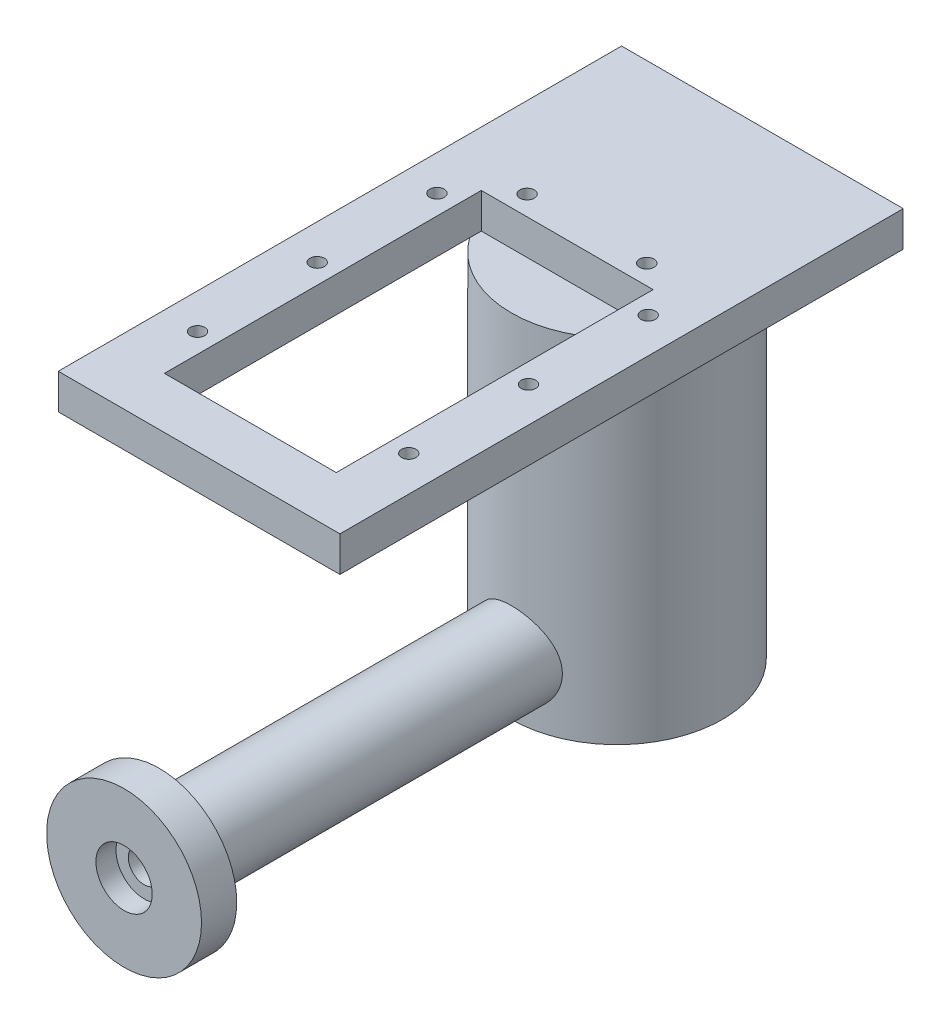
from build123d import *

# Parameters (mm, degrees)
SKETCH1_R                            = 15
BOSS_EXTRUDE1_DEPTH                  = 50
SKETCH2_R                            = 6
BOSS_EXTRUDE2_DEPTH                  = 50
BOSS_EXTRUDE2_DIRECTION_2_REACH      = 62.208
BOSS_EXTRUDE2_DIRECTION_2_END_RADIUS = 15
SKETCH6_R                            = 11
BOSS_EXTRUDE4_DEPTH                  = 5
SKETCH7_W                            = 40
SKETCH7_H                            = 80
SKETCH7_W_2                          = 24.4
SKETCH7_H_2                          = 45
BOSS_EXTRUDE5_DEPTH                  = 5
SKETCH8_R                            = 1.025
CUT_EXTRUDE3_DEPTH                   = 5
SKETCH9_R                            = 4
CUT_EXTRUDE4_DEPTH                   = 2.85
SKETCH10_R                           = 2.25
CUT_EXTRUDE5_DEPTH                   = 2.5


with BuildPart() as part:
    # Sketch1 → Boss-Extrude1 (new body)
    with BuildSketch(Plane(origin=(0, 0, 0), x_dir=(1, 0, 0), z_dir=(0, 1, 0))):
        with Locations(Location((0, 0, 0), (0, 0, 270))):
            Circle(SKETCH1_R)
    extrude(amount=BOSS_EXTRUDE1_DEPTH)

    # Sketch7 → Boss-Extrude5 (add)
    with BuildSketch(Plane(origin=(0, 50, 0), x_dir=(1, 0, 0), z_dir=(0, 1, 0))):
        with Locations((0, -19.344671948)):
            Rectangle(SKETCH7_W, SKETCH7_H)
        with Locations((0, -29.568049779)):
            Rectangle(SKETCH7_W_2, SKETCH7_H_2, mode=Mode.SUBTRACT)
    extrude(amount=BOSS_EXTRUDE5_DEPTH)

    # Sketch8 → Cut-Extrude3 (cut)
    with BuildSketch(Plane(origin=(0, 55, 0), x_dir=(1, 0, 0), z_dir=(0, 1, 0))):
        with Locations(Location((15, -44.568049778, 0), (0, 0, 270))):
            Circle(SKETCH8_R)
        with Locations(Location((15, -27.568049778, 0), (0, 0, 270))):
            Circle(SKETCH8_R)
        with Locations(Location((15, -10.568049778, 0), (0, 0, 270))):
            Circle(SKETCH8_R)
        with Locations(Location((8.5, -4.268049778, 0), (0, 0, 270))):
            Circle(SKETCH8_R)
        with Locations(Location((-8.5, -4.268049778, 0), (0, 0, 270))):
            Circle(SKETCH8_R)
        with Locations(Location((-15, -10.568049778, 0), (0, 0, 270))):
            Circle(SKETCH8_R)
        with Locations(Location((-15, -27.568049778, 0), (0, 0, 270))):
            Circle(SKETCH8_R)
        with Locations(Location((-15, -44.568049778, 0), (0, 0, 270))):
            Circle(SKETCH8_R)
    extrude(amount=-CUT_EXTRUDE3_DEPTH, mode=Mode.SUBTRACT)


with BuildPart() as body_2:
    # Sketch2 → Boss-Extrude2 (new body)
    with BuildSketch(Plane.XY.offset(15)):
        with Locations((0, 8)):
            Circle(SKETCH2_R)
    extrude(amount=BOSS_EXTRUDE2_DEPTH)

    # Boss-Extrude2 direction 2: up to this cylinder (the profile starts outside it)
    boss_extrude2_direction_2_end = Plane(origin=(0, 8, 0), z_dir=(0, -1, 0)) * Cylinder(BOSS_EXTRUDE2_DIRECTION_2_END_RADIUS, 155.416, mode=Mode.PRIVATE)
    # Sketch2 → Boss-Extrude2 direction 2 (add, up to the surface)
    with BuildSketch(Plane.XY.offset(15), mode=Mode.PRIVATE) as boss_extrude2_direction_2_sk1:
        with Locations((0, 8)):
            Circle(SKETCH2_R)
    boss_extrude2_direction_2_tool1 = extrude(boss_extrude2_direction_2_sk1.sketch, amount=-BOSS_EXTRUDE2_DIRECTION_2_REACH, mode=Mode.PRIVATE) - boss_extrude2_direction_2_end
    add(boss_extrude2_direction_2_tool1.solids().sort_by_distance((0, 8, 15))[0])
    add(boss_extrude2_direction_2_tool1.solids().sort_by_distance((0, 8, 15))[1])

    # Sketch6 → Boss-Extrude4 (add)
    with BuildSketch(Plane.XY.offset(65)):
        with Locations((0, 8)):
            Circle(SKETCH6_R)
    extrude(amount=BOSS_EXTRUDE4_DEPTH)

    # Sketch9 → Cut-Extrude4 (cut)
    with BuildSketch(Plane.XY.offset(70)):
        with Locations((0, 8)):
            Circle(SKETCH9_R)
    extrude(amount=-CUT_EXTRUDE4_DEPTH, mode=Mode.SUBTRACT)

    # Sketch10 → Cut-Extrude5 (cut)
    with BuildSketch(Plane.XY.offset(67.15)):
        with Locations((0, 8)):
            Circle(SKETCH10_R)
    extrude(amount=-CUT_EXTRUDE5_DEPTH, mode=Mode.SUBTRACT)


solid = Compound([part.part, body_2.part])
